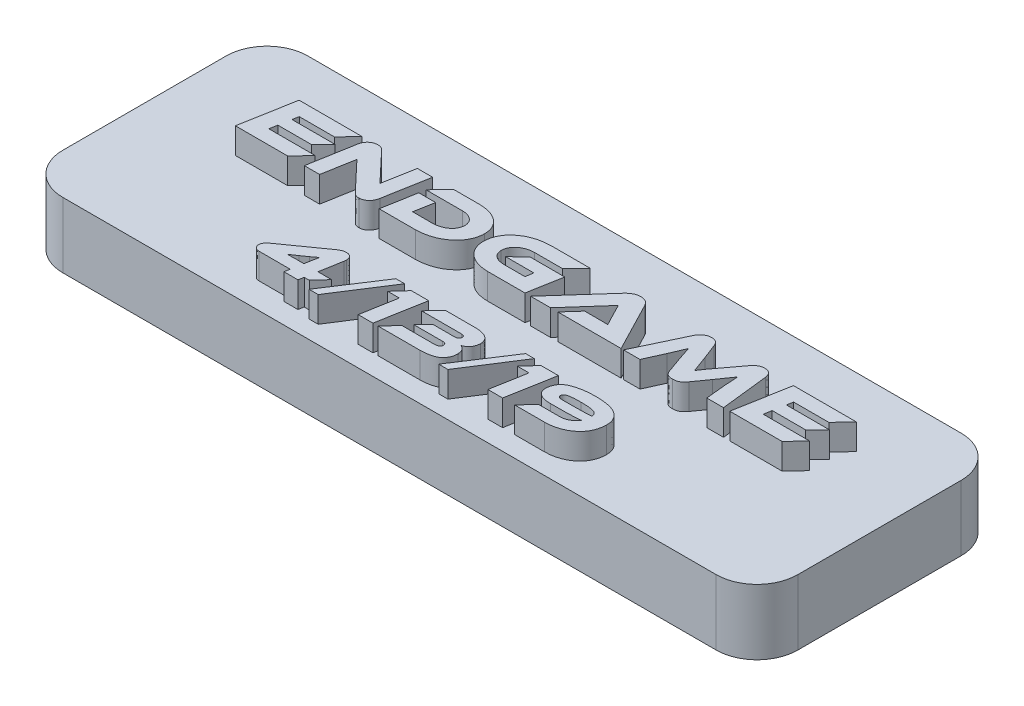
from build123d import *

# Parameters (mm, degrees)
SKETCH1_W           = 57.15
SKETCH1_H           = 19.05
BOSS_EXTRUDE1_DEPTH = 5.08
FILLET1_R           = 3.175
BOSS_EXTRUDE2_DEPTH = 2
SKETCH4_R           = 0.9
CUT_EXTRUDE1_DEPTH  = 4


with BuildPart() as part:
    # Sketch1 → Boss-Extrude1 (new body)
    with BuildSketch(Plane(origin=(0, 0, 0), x_dir=(1, 0, 0), z_dir=(0, 1, 0))):
        Rectangle(SKETCH1_W, SKETCH1_H)
    extrude(amount=BOSS_EXTRUDE1_DEPTH)

    # Fillet1
    fillet1_edges = [part.edges().sort_by_distance(p)[0] for p in [
        (-28.575, 2.54, -9.525),
        (-28.575, 2.54, 9.525),
        (28.575, 2.54, 9.525),
        (28.575, 2.54, -9.525),
    ]]
    fillet(fillet1_edges, radius=FILLET1_R)

    # Sketch3 → Boss-Extrude2 (add)
    with BuildSketch(Plane(origin=(0, 5.08, 0), x_dir=(1, 0, 0), z_dir=(0, 1, 0))):
        Polygon((18.429854665, 1.105536066), (18.530954449, 1.700326644), (21.13427389, 1.700326644), (22.044171947, 2.629107706), (18.701560334, 2.629107706), (18.790022645, 3.106887389), (21.526035553, 3.106887389), (22.568627077, 4.206347541), (17.67792502, 4.206347541), (16.925995376, 0.006075914), (20.995261687, 0.006075914), (22.031534474, 1.105536066), align=None)
        with BuildLine():
            add(Edge.make_bspline(
                [(11.894768833, 3.821864298), (11.880737461, 3.854947842), (11.853285062, 3.919675843), (11.798988796, 4.00785825), (11.735456865, 4.084680144), (11.662386911, 4.150072297), (11.577518363, 4.202261522), (11.480660996, 4.239681634), (11.371815878, 4.261491707), (11.295700389, 4.264690453), (11.255985459, 4.266359469)],
                knots=[0, 0, 0, 0, 0.000107692, 0.0002107, 0.00030937, 0.000405859, 0.000503537, 0.000606581, 0.000715765, 0.000834889, 0.000834889, 0.000834889, 0.000834889], degree=3))
            add(Edge.make_bspline(
                [(11.255985459, 4.266359469), (11.214706682, 4.264911976), (11.13219538, 4.262018611), (11.010430174, 4.234270285), (10.892028221, 4.188827027), (10.778036614, 4.125361681), (10.668900145, 4.045413244), (10.572082708, 3.943118147), (10.482019182, 3.825335584), (10.43414462, 3.735707046), (10.409478309, 3.689527923)],
                knots=[0, 0, 0, 0, 0.000123685, 0.000247231, 0.000372524, 0.000503046, 0.00063761, 0.000776601, 0.000924145, 0.00108096, 0.00108096, 0.00108096, 0.00108096], degree=3))
            Line((10.409478309, 3.689527923), (8.665894478, 0.003655726))
            Line((8.665894478, 0.003655726), (9.948597989, 0.003655726))
            Line((9.948597989, 0.003655726), (10.605746585, 1.464481009))
            add(Edge.make_bspline(
                [(10.605746585, 1.464481009), (10.629976343, 1.519909601), (10.677604369, 1.628864646), (10.746475763, 1.789446184), (10.81374685, 1.942964846), (10.876502056, 2.090413825), (10.937079718, 2.230959426), (10.993771815, 2.365338229), (11.046652072, 2.493505747), (11.081070868, 2.576699716), (11.097836715, 2.617224589)],
                knots=[0, 0, 0, 0, 0.000181479, 0.000356729, 0.00052418, 0.000684305, 0.000837469, 0.000983313, 0.001121843, 0.001253412, 0.001253412, 0.001253412, 0.001253412], degree=3))
            add(Edge.make_bspline(
                [(11.097836715, 2.617224589), (11.108081431, 2.582146896), (11.129323951, 2.509412955), (11.164696468, 2.396952832), (11.201420628, 2.276154433), (11.244755778, 2.146346616), (11.292640294, 2.002632754), (11.348718581, 1.841123618), (11.413859329, 1.659810645), (11.459560152, 1.531826555), (11.483609952, 1.464475652)],
                knots=[0, 0, 0, 0, 0.000109626, 0.000227311, 0.000353666, 0.000488379, 0.000637834, 0.000808115, 0.001001264, 0.001215812, 0.001215812, 0.001215812, 0.001215812], degree=3))
            Line((11.483609952, 1.464475652), (11.86317515, 0.404912456))
            add(Edge.make_bspline(
                [(11.86317515, 0.404912456), (11.881349857, 0.359535583), (11.915305273, 0.27475894), (11.981270271, 0.165066891), (12.052568902, 0.079389949), (12.133630324, 0.020148619), (12.222151269, -0.017188774), (12.317484931, -0.042938659), (12.422049706, -0.056575195), (12.494630096, -0.05604004), (12.532145266, -0.05576343)],
                knots=[0, 0, 0, 0, 0.000146435, 0.000273581, 0.000382454, 0.000478632, 0.000571543, 0.000669118, 0.00077423, 0.000886686, 0.000886686, 0.000886686, 0.000886686], degree=3))
            add(Edge.make_bspline(
                [(12.532145266, -0.05576343), (12.569961467, -0.055992745), (12.644351441, -0.056443841), (12.753780632, -0.042717291), (12.857894085, -0.015563104), (12.959959217, 0.022829401), (13.061143184, 0.083036928), (13.162366171, 0.169070984), (13.266819016, 0.280708265), (13.331989983, 0.367692811), (13.366768406, 0.414112029)],
                knots=[0, 0, 0, 0, 0.00011337, 0.000223015, 0.000329662, 0.000435594, 0.000549104, 0.000680897, 0.00083287, 0.001006773, 0.001006773, 0.001006773, 0.001006773], degree=3))
            Line((13.366768406, 0.414112029), (14.118964083, 1.465200548))
            add(Edge.make_bspline(
                [(14.118964083, 1.465200548), (14.165146382, 1.529169794), (14.253544614, 1.651614289), (14.378329736, 1.828381807), (14.492043038, 1.987679293), (14.592602712, 2.133154937), (14.684430967, 2.266547935), (14.769117851, 2.390994455), (14.847251286, 2.508743118), (14.896811327, 2.584889894), (14.920831208, 2.621795362)],
                knots=[0, 0, 0, 0, 0.000236691, 0.000453055, 0.000649121, 0.000823842, 0.000983589, 0.001134958, 0.00127542, 0.001407521, 0.001407521, 0.001407521, 0.001407521], degree=3))
            add(Edge.make_bspline(
                [(14.920831208, 2.621795362), (14.923065179, 2.536757041), (14.927655935, 2.362005428), (14.941696449, 2.139966033), (14.954363921, 1.952236415), (14.967941561, 1.800289613), (14.981123904, 1.638717755), (14.991416816, 1.52784762), (14.996706039, 1.470874734)],
                knots=[0, 0, 0, 0, 0.000255182, 0.000524392, 0.000667354, 0.000819643, 0.000982028, 0.00115368, 0.00115368, 0.00115368, 0.00115368], degree=3))
            Line((14.996706039, 1.470874734), (15.142599398, 0.003655726))
            Line((15.142599398, 0.003655726), (16.444259118, 0.003655726))
            Line((16.444259118, 0.003655726), (16.027222509, 3.690201933))
            add(Edge.make_bspline(
                [(16.027222509, 3.690201933), (16.019857111, 3.735767572), (16.005783628, 3.822832418), (15.960936809, 3.942054526), (15.901954619, 4.044898175), (15.822923496, 4.125995793), (15.73265053, 4.189905999), (15.631096195, 4.235155569), (15.519214696, 4.262540065), (15.44114713, 4.265057293), (15.400762367, 4.266359469)],
                knots=[0, 0, 0, 0, 0.000138154, 0.000263979, 0.000379994, 0.000491206, 0.000600771, 0.000710019, 0.000822876, 0.000943824, 0.000943824, 0.000943824, 0.000943824], degree=3))
            add(Edge.make_bspline(
                [(15.400762367, 4.266359469), (15.358916862, 4.264315029), (15.277042771, 4.26031492), (15.158115287, 4.237458819), (15.047211105, 4.198932407), (14.945190224, 4.144580626), (14.849604654, 4.0797862), (14.762121925, 4.002630646), (14.678413771, 3.917859546), (14.63004088, 3.853756483), (14.605447874, 3.821166184)],
                knots=[0, 0, 0, 0, 0.000125572, 0.000245692, 0.000361916, 0.000476404, 0.000591519, 0.00070753, 0.000825838, 0.000948192, 0.000948192, 0.000948192, 0.000948192], degree=3))
            Line((14.605447874, 3.821166184), (13.714564947, 2.63063338))
            add(Edge.make_bspline(
                [(13.714564947, 2.63063338), (13.685472724, 2.592038973), (13.628867352, 2.516944994), (13.546514277, 2.40752977), (13.469984999, 2.303579542), (13.396432362, 2.207146967), (13.328694504, 2.115786728), (13.267011313, 2.029366729), (13.208270311, 1.950451781), (13.138704278, 1.854220433), (13.058823945, 1.742020151), (12.970171015, 1.614517972), (12.890683501, 1.49522478), (12.840481428, 1.418793145), (12.816447343, 1.382201739)],
                knots=[0, 0, 0, 0, 0.000144993, 0.000282116, 0.00041083, 0.000532231, 0.000645954, 0.000752012, 0.000850745, 0.000941075, 0.001108235, 0.001263934, 0.001406932, 0.001538268, 0.001538268, 0.001538268, 0.001538268], degree=3))
            add(Edge.make_bspline(
                [(12.816447343, 1.382201739), (12.80437003, 1.418805813), (12.778644152, 1.496776135), (12.735411884, 1.619692211), (12.687083553, 1.756361741), (12.631857618, 1.906038253), (12.57182889, 2.069898911), (12.504908525, 2.24675863), (12.432783261, 2.43736016), (12.382008888, 2.568503977), (12.35571343, 2.636421836)],
                knots=[0, 0, 0, 0, 0.000115632, 0.000246309, 0.000390878, 0.000550518, 0.00072492, 0.000914406, 0.001117803, 0.001336294, 0.001336294, 0.001336294, 0.001336294], degree=3))
            Line((12.35571343, 2.636421836), (11.894768833, 3.821864298))
        make_face()
        with BuildLine():
            Line((8.477148337, 0.006075914), (6.512021283, 3.800574494))
            add(Edge.make_bspline(
                [(6.512021283, 3.800574494), (6.493900339, 3.832806008), (6.457941675, 3.896765269), (6.393067986, 3.985575321), (6.315808499, 4.0630874), (6.230905587, 4.133983071), (6.133099693, 4.192399523), (6.020988544, 4.23493807), (5.894946717, 4.260058315), (5.806215784, 4.264204191), (5.760088068, 4.266359469)],
                knots=[0, 0, 0, 0, 0.000110886, 0.000220038, 0.000328642, 0.000438436, 0.000551159, 0.000668641, 0.000796469, 0.000934872, 0.000934872, 0.000934872, 0.000934872], degree=3))
            add(Edge.make_bspline(
                [(5.760088068, 4.266359469), (5.710276408, 4.264009128), (5.613545287, 4.259444915), (5.473506531, 4.230967468), (5.343227969, 4.187726952), (5.223493094, 4.126959855), (5.113811438, 4.055096369), (5.010610085, 3.977511138), (4.916303872, 3.892229282), (4.858921369, 3.830720556), (4.83039285, 3.800140628)],
                knots=[0, 0, 0, 0, 0.00014941, 0.000290146, 0.000427171, 0.000560039, 0.000691642, 0.000820174, 0.000947034, 0.001072464, 0.001072464, 0.001072464, 0.001072464], degree=3))
            Line((4.83039285, 3.800140628), (1.444394604, 0.006075914))
            Line((1.444394604, 0.006075914), (2.992485048, 0.006075914))
            Line((2.992485048, 0.006075914), (5.469429759, 2.798493231))
            Line((5.469429759, 2.798493231), (6.031797308, 1.696826253))
            add(Edge.make_bspline(
                [(6.031797308, 1.696826253), (6.058471313, 1.644325557), (6.11298756, 1.5370248), (6.182415901, 1.403208105), (6.238498996, 1.297464771), (6.27964011, 1.223921613), (6.316043952, 1.155498073), (6.341342257, 1.112747401), (6.353374396, 1.092414734)],
                knots=[0, 0, 0, 0, 0.000176664, 0.000361065, 0.000452265, 0.000535729, 0.000613867, 0.000684736, 0.000684736, 0.000684736, 0.000684736], degree=3))
            add(Edge.make_bspline(
                [(6.353374396, 1.092414734), (6.297926051, 1.095166522), (6.179766216, 1.101030553), (5.995335681, 1.103502684), (5.800316815, 1.10564963), (5.668064218, 1.105358474), (5.601939324, 1.105212899)],
                knots=[0, 0, 0, 0, 0.000166537, 0.000354888, 0.000553268, 0.00075164, 0.00075164, 0.00075164, 0.00075164], degree=3))
            Line((5.601939324, 1.105212899), (4.546894229, 1.105536066))
            Line((4.546894229, 1.105536066), (3.561171334, 0.006075914))
            Line((3.561171334, 0.006075914), (8.477148337, 0.006075914))
        make_face()
        with BuildLine():
            Line((-2.188548578, 1.700326644), (0.00405299, 1.700326644))
            Line((0.00405299, 1.700326644), (-0.103365531, 1.105536066))
            Line((-0.103365531, 1.105536066), (-1.708324603, 1.105536066))
            add(Edge.make_bspline(
                [(-1.708324603, 1.105536066), (-1.748659925, 1.106330575), (-1.826997637, 1.10787364), (-1.941221904, 1.120440798), (-2.049065069, 1.138380554), (-2.150986128, 1.162855529), (-2.246335932, 1.194526626), (-2.334676568, 1.23455811), (-2.417480793, 1.27991048), (-2.493016882, 1.332827412), (-2.561129732, 1.391530884), (-2.621040822, 1.45559712), (-2.671500218, 1.52543391), (-2.713027543, 1.600393879), (-2.746069226, 1.680070217), (-2.769940723, 1.76505151), (-2.784594748, 1.855247878), (-2.787564667, 1.917233088), (-2.789085652, 1.948977585)],
                knots=[0, 0, 0, 0, 0.000120973, 0.00023495, 0.000344358, 0.000448788, 0.0005491, 0.00064526, 0.000739378, 0.000831943, 0.00092138, 0.001008705, 0.001094465, 0.001179171, 0.001265243, 0.001352639, 0.001443412, 0.001538699, 0.001538699, 0.001538699, 0.001538699], degree=3))
            add(Edge.make_bspline(
                [(-2.789085652, 1.948977585), (-2.786677572, 1.990521625), (-2.781933102, 2.072372891), (-2.758644466, 2.191747965), (-2.722646493, 2.305058921), (-2.675012901, 2.412475984), (-2.615297376, 2.514029002), (-2.542081222, 2.608456756), (-2.457439217, 2.697788244), (-2.360985687, 2.780121784), (-2.25556478, 2.8545346), (-2.14321074, 2.919811261), (-2.025243628, 2.975666019), (-1.901346883, 3.021489762), (-1.771588416, 3.057113773), (-1.635897555, 3.083377984), (-1.494184303, 3.101324142), (-1.397491818, 3.104622124), (-1.348378019, 3.106297295)],
                knots=[0, 0, 0, 0, 0.000124731, 0.000245749, 0.000363706, 0.00048075, 0.000597551, 0.000716215, 0.000838429, 0.000966139, 0.001096001, 0.001225039, 0.001355485, 0.001487088, 0.001620824, 0.001758691, 0.001901446, 0.002048806, 0.002048806, 0.002048806, 0.002048806], degree=3))
            Line((-1.348378019, 3.106297295), (0.831807473, 3.106887389))
            Line((0.831807473, 3.106887389), (1.874398996, 4.206347541))
            Line((1.874398996, 4.206347541), (-1.152275791, 4.206347541))
            add(Edge.make_bspline(
                [(-1.152275791, 4.206347541), (-1.25428659, 4.202659754), (-1.454076857, 4.195437147), (-1.747476329, 4.162798867), (-2.027131297, 4.108387385), (-2.294747671, 4.036898854), (-2.548411799, 3.943701994), (-2.790608821, 3.833597097), (-3.018377644, 3.700931434), (-3.197623245, 3.57590569), (-3.333148697, 3.468283005), (-3.427173439, 3.382481576), (-3.516376135, 3.295042371), (-3.598536123, 3.203531084), (-3.674403958, 3.108944431), (-3.745486418, 3.012406878), (-3.808356226, 2.911044995), (-3.865976767, 2.807132253), (-3.917479582, 2.700195689), (-3.961251359, 2.58966186), (-3.999599141, 2.476141564), (-4.032971617, 2.359497657), (-4.057835907, 2.239261797), (-4.078728774, 2.116507731), (-4.091018403, 1.990322157), (-4.095154311, 1.905118165), (-4.09724087, 1.862132899)],
                knots=[0, 0, 0, 0, 0.000306166, 0.000599632, 0.000884516, 0.001160163, 0.001429692, 0.001694339, 0.001957287, 0.002219254, 0.002349315, 0.002476175, 0.002600933, 0.00272392, 0.002844844, 0.002964612, 0.003083315, 0.003202384, 0.00332096, 0.003439109, 0.00355879, 0.003680341, 0.0038028, 0.003926937, 0.004053738, 0.004182841, 0.004182841, 0.004182841, 0.004182841], degree=3))
            add(Edge.make_bspline(
                [(-4.09724087, 1.862132899), (-4.094285472, 1.796195871), (-4.088495023, 1.667006815), (-4.057611951, 1.477974695), (-4.009464116, 1.297945273), (-3.942139409, 1.127082415), (-3.857736722, 0.964958447), (-3.754515321, 0.812395591), (-3.63298937, 0.669127744), (-3.494014468, 0.53618193), (-3.340474291, 0.41483463), (-3.172272609, 0.309152307), (-2.991924524, 0.218154431), (-2.797635671, 0.144712183), (-2.591482403, 0.084613249), (-2.371642784, 0.042790936), (-2.13957588, 0.013380205), (-1.980152443, 0.008154744), (-1.898699082, 0.005484928)],
                knots=[0, 0, 0, 0, 0.000197872, 0.000387686, 0.000573295, 0.000755955, 0.000937501, 0.001120561, 0.001307371, 0.001500038, 0.001696635, 0.001893441, 0.002094991, 0.002301602, 0.002515698, 0.002738365, 0.002972284, 0.003216652, 0.003216652, 0.003216652, 0.003216652], degree=3))
            Line((-1.898699082, 0.005484928), (1.002413358, 0.006075914))
            Line((1.002413358, 0.006075914), (1.46999986, 2.629107706))
            Line((1.46999986, 2.629107706), (-1.234419365, 2.629107706))
            Line((-1.234419365, 2.629107706), (-2.188548578, 1.700326644))
        make_face()
        with BuildLine():
            add(Edge.make_bspline(
                [(-4.549788457, 2.425376215), (-4.552664171, 2.490366785), (-4.558314581, 2.618064917), (-4.590121961, 2.803986167), (-4.638752569, 2.980115123), (-4.704286136, 3.146960648), (-4.790483292, 3.303299496), (-4.893914923, 3.450058323), (-5.016157304, 3.586303096), (-5.154716397, 3.712179584), (-5.3097238, 3.825344313), (-5.478138165, 3.925395962), (-5.6603537, 4.009390478), (-5.855217237, 4.079106767), (-6.063287079, 4.133528035), (-6.284486131, 4.173811565), (-6.518925776, 4.198189582), (-6.679671791, 4.203371321), (-6.762001498, 4.206025266)],
                knots=[0, 0, 0, 0, 0.000195009, 0.000383167, 0.000564368, 0.00074244, 0.000919581, 0.001098646, 0.001279935, 0.00146761, 0.001659228, 0.001854731, 0.002054318, 0.002260196, 0.002474835, 0.002698788, 0.00293411, 0.003181175, 0.003181175, 0.003181175, 0.003181175], degree=3))
            Line((-6.762001498, 4.206025266), (-8.758066971, 4.206347541))
            Line((-8.758066971, 4.206347541), (-9.788021021, 3.106887389))
            Line((-9.788021021, 3.106887389), (-6.957227066, 3.106887389))
            add(Edge.make_bspline(
                [(-6.957227066, 3.106887389), (-6.917715166, 3.105364711), (-6.840498924, 3.102389015), (-6.727877278, 3.089591847), (-6.621184262, 3.069582481), (-6.520335905, 3.04202105), (-6.424973819, 3.008030543), (-6.33684342, 2.964107485), (-6.253980142, 2.914773344), (-6.177216806, 2.858665576), (-6.109302126, 2.795181395), (-6.047623598, 2.72884043), (-5.99779337, 2.655711823), (-5.954979536, 2.579167986), (-5.920748824, 2.49778013), (-5.897753084, 2.411231968), (-5.881221869, 2.320728819), (-5.878495151, 2.258648084), (-5.877099855, 2.22688058)],
                knots=[0, 0, 0, 0, 0.000118592, 0.000231759, 0.000339692, 0.000443921, 0.000545141, 0.000642853, 0.0007388, 0.00083424, 0.000927403, 0.001017368, 0.001105364, 0.001192113, 0.001280223, 0.00136938, 0.001460305, 0.001555592, 0.001555592, 0.001555592, 0.001555592], degree=3))
            add(Edge.make_bspline(
                [(-5.877099855, 2.22688058), (-5.879544299, 2.185642711), (-5.884339039, 2.104755276), (-5.90687974, 1.98706422), (-5.940385994, 1.87545354), (-5.987513464, 1.770616802), (-6.046759093, 1.672112744), (-6.117047485, 1.579018173), (-6.201626674, 1.493971369), (-6.296064761, 1.414841832), (-6.400282041, 1.343689091), (-6.51193689, 1.281927096), (-6.629570344, 1.227960987), (-6.7548401, 1.185692043), (-6.886001438, 1.150471437), (-7.024349532, 1.126576329), (-7.168676339, 1.109169924), (-7.267474717, 1.106548421), (-7.317807488, 1.105212899)],
                knots=[0, 0, 0, 0, 0.00012382, 0.000242871, 0.000358539, 0.000472706, 0.000586683, 0.000702784, 0.000821729, 0.000945681, 0.001071953, 0.001199634, 0.001328098, 0.001459638, 0.001595783, 0.001735109, 0.00188048, 0.002031451, 0.002031451, 0.002031451, 0.002031451], degree=3))
            Line((-7.317807488, 1.105212899), (-8.833891809, 1.105536066))
            Line((-8.833891809, 1.105536066), (-8.562186139, 2.623662059))
            Line((-8.562186139, 2.623662059), (-9.870164596, 2.623662059))
            Line((-9.870164596, 2.623662059), (-10.337751098, 0.006075914))
            Line((-10.337751098, 0.006075914), (-7.506957142, 0.006075914))
            add(Edge.make_bspline(
                [(-7.506957142, 0.006075914), (-7.405089766, 0.00973645), (-7.204933829, 0.016928919), (-6.911556149, 0.055361686), (-6.630962616, 0.113609118), (-6.363086093, 0.192345638), (-6.107644027, 0.290947451), (-5.865467495, 0.411678855), (-5.635016854, 0.551302588), (-5.455642372, 0.685730436), (-5.320356032, 0.801137626), (-5.225165418, 0.891127884), (-5.135674869, 0.98286194), (-5.052781552, 1.077854124), (-4.976020105, 1.175378809), (-4.905844438, 1.275986307), (-4.841116497, 1.378755373), (-4.783986165, 1.484675691), (-4.732411112, 1.592866707), (-4.687522842, 1.703675086), (-4.649315903, 1.817381495), (-4.616218488, 1.933500983), (-4.589362309, 2.052449268), (-4.570885156, 2.174419147), (-4.556452898, 2.298802205), (-4.552603178, 2.38285802), (-4.549788457, 2.425376215)],
                knots=[0, 0, 0, 0, 0.000305659, 0.00060058, 0.000886364, 0.001164634, 0.001437273, 0.001706688, 0.001975409, 0.002244537, 0.002378097, 0.002508729, 0.002637378, 0.002762417, 0.002886772, 0.003009517, 0.003130255, 0.003250927, 0.003370328, 0.003489667, 0.003609348, 0.003730019, 0.003851781, 0.003974869, 0.004099948, 0.004227226, 0.004227226, 0.004227226, 0.004227226], degree=3))
        make_face()
        with BuildLine():
            add(Edge.make_bspline(
                [(-11.858368697, -0.054850168), (-11.8106253, -0.053307756), (-11.715923158, -0.05024828), (-11.577866776, -0.013632566), (-11.446952065, 0.045846546), (-11.345686531, 0.114571327), (-11.268821867, 0.180074196), (-11.217169586, 0.239380304), (-11.169493599, 0.304525883), (-11.125814852, 0.37632488), (-11.089085217, 0.456142621), (-11.055968596, 0.542520209), (-11.027538943, 0.636006561), (-11.012992869, 0.701351948), (-11.005507101, 0.73498029)],
                knots=[0, 0, 0, 0, 0.000142918, 0.000283487, 0.000425039, 0.000572601, 0.000649052, 0.000727397, 0.000807848, 0.000891096, 0.000979017, 0.001071034, 0.001168489, 0.001271817, 0.001271817, 0.001271817, 0.001271817], degree=3))
            Line((-11.005507101, 0.73498029), (-10.379784354, 4.208766837))
            Line((-10.379784354, 4.208766837), (-11.567706818, 4.208766837))
            Line((-11.567706818, 4.208766837), (-12.010018373, 1.744535481))
            Line((-12.010018373, 1.744535481), (-14.189982468, 4.051761679))
            add(Edge.make_bspline(
                [(-14.189982468, 4.051761679), (-14.210821595, 4.071861366), (-14.250885868, 4.110504029), (-14.313463732, 4.159915527), (-14.375501478, 4.198286334), (-14.45533886, 4.234148727), (-14.555615428, 4.262967857), (-14.636937859, 4.265244744), (-14.676751932, 4.266359469)],
                knots=[0, 0, 0, 0, 8.6821e-05, 0.000166918, 0.000238724, 0.000304999, 0.000429193, 0.000548317, 0.000548317, 0.000548317, 0.000548317], degree=3))
            add(Edge.make_bspline(
                [(-14.676751932, 4.266359469), (-14.726028977, 4.264808905), (-14.823075565, 4.261755212), (-14.964218277, 4.225895662), (-15.097953982, 4.169094021), (-15.200512985, 4.10078741), (-15.277028217, 4.035125752), (-15.328903582, 3.976716804), (-15.377051971, 3.912614286), (-15.419114668, 3.840326612), (-15.456430267, 3.76109782), (-15.488001593, 3.674633708), (-15.516216378, 3.581734028), (-15.529299031, 3.516584051), (-15.536057246, 3.482928986)],
                knots=[0, 0, 0, 0, 0.000147522, 0.000290531, 0.000433852, 0.000581668, 0.000658119, 0.000735785, 0.0008155, 0.00089828, 0.000986201, 0.001077895, 0.001174211, 0.001277134, 0.001277134, 0.001277134, 0.001277134], degree=3))
            Line((-15.536057246, 3.482928986), (-16.148790785, 0.003655726))
            Line((-16.148790785, 0.003655726), (-14.960868322, 0.003655726))
            Line((-14.960868322, 0.003655726), (-14.524875503, 2.467622834))
            Line((-14.524875503, 2.467622834), (-12.344911408, 0.160396636))
            add(Edge.make_bspline(
                [(-12.344911408, 0.160396636), (-12.324194302, 0.140042889), (-12.284589404, 0.101132624), (-12.222457852, 0.052046216), (-12.162898025, 0.012533377), (-12.085369154, -0.024191848), (-11.983674973, -0.051598076), (-11.900645209, -0.054359084), (-11.858368697, -0.054850168)],
                knots=[0, 0, 0, 0, 8.7067e-05, 0.000166446, 0.000237191, 0.000300979, 0.000423168, 0.000549653, 0.000549653, 0.000549653, 0.000549653], degree=3))
        make_face()
        Polygon((-20.008517509, 1.105536066), (-19.907417725, 1.700326644), (-17.304098284, 1.700326644), (-16.394200227, 2.629107706), (-19.73681184, 2.629107706), (-19.648349528, 3.106887389), (-16.912336621, 3.106887389), (-15.869745097, 4.206347541), (-20.760447154, 4.206347541), (-21.512376798, 0.006075914), (-17.443110487, 0.006075914), (-16.4068377, 1.105536066), align=None)
        with BuildLine():
            Line((9.037471648, -6.970155942), (8.142215687, -7.932183575))
            Line((8.142215687, -7.932183575), (10.460393327, -7.932183575))
            add(Edge.make_bspline(
                [(10.460393327, -7.932183575), (10.550239584, -7.929777147), (10.726809287, -7.92504793), (10.98582015, -7.89377972), (11.233859481, -7.845456505), (11.470347796, -7.778119368), (11.695620596, -7.693257531), (11.909297067, -7.589683886), (12.111380515, -7.467776465), (12.269561576, -7.351552012), (12.388796868, -7.251102183), (12.472146657, -7.171271707), (12.550671676, -7.089073015), (12.623886864, -7.003301544), (12.690626319, -6.913691428), (12.752960305, -6.821436558), (12.808521776, -6.725101624), (12.860176433, -6.626227548), (12.904835848, -6.523415525), (12.944006789, -6.417304195), (12.978646885, -6.308297587), (13.006250776, -6.195383605), (13.030001976, -6.079711014), (13.046047681, -5.960192069), (13.058685586, -5.837767761), (13.062033514, -5.75491021), (13.063726159, -5.713019076)],
                knots=[0, 0, 0, 0, 0.000269512, 0.000529657, 0.000781592, 0.001026938, 0.001266417, 0.001502887, 0.001738287, 0.001973466, 0.00209094, 0.002205793, 0.002319514, 0.002431869, 0.002543853, 0.002654555, 0.002765679, 0.002877297, 0.002989052, 0.003101677, 0.003216532, 0.003331962, 0.003450243, 0.003570604, 0.003693573, 0.003819318, 0.003819318, 0.003819318, 0.003819318], degree=3))
            add(Edge.make_bspline(
                [(13.063726159, -5.713019076), (13.061601039, -5.652117472), (13.057467249, -5.533651456), (13.029078622, -5.361744864), (12.98278984, -5.20161806), (12.918568557, -5.05300733), (12.835950893, -4.916595218), (12.736422554, -4.79126316), (12.616721793, -4.67984859), (12.481267506, -4.578328397), (12.326565022, -4.490460709), (12.154830881, -4.413762538), (11.96515105, -4.349318484), (11.758087074, -4.296844754), (11.533226109, -4.256528236), (11.290716399, -4.227593809), (11.030455012, -4.208531898), (10.851012539, -4.206884801), (10.758456824, -4.206035236)],
                knots=[0, 0, 0, 0, 0.00018267, 0.00035533, 0.000521131, 0.000681619, 0.000839513, 0.000998287, 0.001160113, 0.00132873, 0.001505033, 0.001692644, 0.001892226, 0.002105242, 0.002332894, 0.00257706, 0.002837673, 0.00311529, 0.00311529, 0.00311529, 0.00311529], degree=3))
            add(Edge.make_bspline(
                [(10.758456824, -4.206035236), (10.675257969, -4.205592276), (10.51171914, -4.204721577), (10.270480518, -4.215578286), (10.037659691, -4.234927868), (9.813233539, -4.265660573), (9.59708624, -4.305110003), (9.389664698, -4.355643498), (9.190744491, -4.415783415), (9.031299974, -4.473503284), (8.909439756, -4.525130752), (8.824973411, -4.569635858), (8.744965734, -4.616422557), (8.671758705, -4.668834502), (8.602879168, -4.723868288), (8.540670879, -4.784450305), (8.482703114, -4.847987079), (8.431338059, -4.916899938), (8.384956473, -4.989145242), (8.344775614, -5.066161285), (8.30953322, -5.146801308), (8.279968113, -5.2318633), (8.255964093, -5.32088445), (8.237698564, -5.41389817), (8.224674951, -5.510872203), (8.220794612, -5.57700115), (8.218821105, -5.610633762)],
                knots=[0, 0, 0, 0, 0.000249565, 0.000490555, 0.000724179, 0.0009502, 0.001169841, 0.001383052, 0.001590297, 0.00179299, 0.001891509, 0.001987031, 0.002079216, 0.002169319, 0.002256891, 0.002343445, 0.002429536, 0.002514644, 0.002600961, 0.002686833, 0.002774954, 0.002864759, 0.002956732, 0.003051325, 0.003148954, 0.003249996, 0.003249996, 0.003249996, 0.003249996], degree=3))
            add(Edge.make_bspline(
                [(8.218821105, -5.610633762), (8.220255959, -5.643753438), (8.223061456, -5.708510641), (8.23894285, -5.802650158), (8.265930264, -5.890402518), (8.300733481, -5.972873051), (8.346850863, -6.048807605), (8.403415213, -6.117637999), (8.469026306, -6.18094304), (8.544490807, -6.237416652), (8.628456868, -6.287658407), (8.72048282, -6.330947125), (8.820089213, -6.367615523), (8.927528008, -6.398128227), (9.042903094, -6.420818141), (9.165761914, -6.437537883), (9.296088771, -6.448004733), (9.385567354, -6.449663014), (9.431447168, -6.450513291)],
                knots=[0, 0, 0, 0, 9.9392e-05, 0.000194336, 0.000285432, 0.000374287, 0.00046222, 0.000550917, 0.000640864, 0.000735091, 0.000833037, 0.000933937, 0.001039728, 0.001151139, 0.001268635, 0.001392165, 0.00152296, 0.001660599, 0.001660599, 0.001660599, 0.001660599], degree=3))
            add(Edge.make_bspline(
                [(9.431447168, -6.450513291), (9.485039674, -6.450588766), (9.589825715, -6.450736339), (9.743402417, -6.449683936), (9.890314733, -6.448934551), (10.030294945, -6.448155746), (10.163608234, -6.447263447), (10.289995913, -6.446777451), (10.409706837, -6.444902162), (10.522758742, -6.443402764), (10.628874015, -6.441665317), (10.728075514, -6.440519694), (10.820568594, -6.437415789), (10.906184612, -6.436504009), (10.985094041, -6.433778787), (11.057080331, -6.43134803), (11.122437058, -6.429349577), (11.199177449, -6.424605461), (11.28643585, -6.420771207), (11.383704275, -6.413793257), (11.472303627, -6.408049685), (11.552177546, -6.400065169), (11.623563214, -6.394706302), (11.685854484, -6.386176476), (11.739515612, -6.378534723), (11.772193577, -6.372485855), (11.787109275, -6.369724879)],
                knots=[0, 0, 0, 0, 0.000160777, 0.000314357, 0.000460738, 0.00060152, 0.000734304, 0.000860688, 0.000980681, 0.001093477, 0.001199873, 0.001299072, 0.00139109, 0.001477493, 0.001555918, 0.001627948, 0.001693582, 0.001752061, 0.001858593, 0.001955591, 0.002044608, 0.00212492, 0.002196397, 0.002259299, 0.002313485, 0.002358987, 0.002358987, 0.002358987, 0.002358987], degree=3))
            add(Edge.make_bspline(
                [(11.787109275, -6.369724879), (11.757388219, -6.410755391), (11.697542947, -6.493372984), (11.589848846, -6.604032197), (11.469924752, -6.70577684), (11.359381789, -6.780745718), (11.264425747, -6.833676621), (11.189625994, -6.868964979), (11.11238554, -6.899761591), (11.031493621, -6.923136897), (10.94841744, -6.943784293), (10.861700027, -6.957621584), (10.772283089, -6.967749518), (10.711558976, -6.969535864), (10.680867953, -6.970438714)],
                knots=[0, 0, 0, 0, 0.000151822, 0.000305704, 0.000461788, 0.000623076, 0.000705429, 0.000787724, 0.000871054, 0.000954565, 0.001040123, 0.001127702, 0.001217802, 0.001309875, 0.001309875, 0.001309875, 0.001309875], degree=3))
            Line((10.680867953, -6.970438714), (9.037471648, -6.970155942))
        make_face()
        with BuildLine():
            add(Edge.make_bspline(
                [(9.647645844, -5.739416071), (9.619260826, -5.739333167), (9.566072111, -5.739177819), (9.492321783, -5.728388524), (9.429434379, -5.712937853), (9.377511234, -5.691097621), (9.336391999, -5.66209877), (9.308177259, -5.625127048), (9.290044971, -5.582069955), (9.288874274, -5.550830586), (9.288267705, -5.534644662)],
                knots=[0, 0, 0, 0, 8.5051e-05, 0.000159372, 0.000223007, 0.000278884, 0.00032752, 0.000371998, 0.000416856, 0.000465088, 0.000465088, 0.000465088, 0.000465088], degree=3))
            add(Edge.make_bspline(
                [(9.288267705, -5.534644662), (9.287065419, -5.520492659), (9.284711493, -5.492784798), (9.292658168, -5.451904192), (9.307938057, -5.413284736), (9.332852391, -5.377865243), (9.365139393, -5.344746874), (9.406404298, -5.315137149), (9.455032714, -5.287204256), (9.513516416, -5.262102266), (9.584011361, -5.239181686), (9.670150249, -5.220969825), (9.772092382, -5.204302076), (9.890363974, -5.19102051), (10.024831798, -5.180808804), (10.175822962, -5.174134861), (10.343015577, -5.169033665), (10.459828414, -5.168550026), (10.5208909, -5.16829721)],
                knots=[0, 0, 0, 0, 4.2424e-05, 8.3061e-05, 0.000123611, 0.000166209, 0.000212026, 0.00026178, 0.000318034, 0.000380003, 0.000452348, 0.000540062, 0.000643816, 0.000762183, 0.000896965, 0.001048315, 0.00121556, 0.00139874, 0.00139874, 0.00139874, 0.00139874], degree=3))
            add(Edge.make_bspline(
                [(10.5208909, -5.16829721), (10.573417429, -5.167787601), (10.675543344, -5.166796781), (10.824088142, -5.169363834), (10.963368239, -5.174373781), (11.093194618, -5.184530804), (11.213890889, -5.195834798), (11.325273517, -5.211544935), (11.427013036, -5.232098586), (11.520225985, -5.253456427), (11.603846744, -5.280784321), (11.677336699, -5.316195779), (11.739979011, -5.359607715), (11.793547245, -5.409671023), (11.835288262, -5.468468051), (11.868142914, -5.534032814), (11.888589751, -5.607713922), (11.894471714, -5.659314386), (11.897493442, -5.685822977)],
                knots=[0, 0, 0, 0, 0.000157579, 0.000306377, 0.00044567, 0.000575606, 0.000696984, 0.000809313, 0.000912848, 0.001008299, 0.001096072, 0.001176204, 0.001252088, 0.00132394, 0.001394981, 0.001467241, 0.001542944, 0.00162292, 0.00162292, 0.00162292, 0.00162292], degree=3))
            add(Edge.make_bspline(
                [(11.897493442, -5.685822977), (11.879902738, -5.688016622), (11.842355272, -5.692698971), (11.782598188, -5.698817251), (11.716023393, -5.705774202), (11.642596325, -5.709867374), (11.562620569, -5.714809123), (11.475984017, -5.719762177), (11.382653256, -5.723691176), (11.279453651, -5.726773296), (11.160283793, -5.730355113), (11.01868678, -5.73231403), (10.851779395, -5.734779827), (10.659809902, -5.737306699), (10.442504427, -5.738848781), (10.199870139, -5.739352636), (9.93190951, -5.740463735), (9.745002328, -5.740300435), (9.647645844, -5.739416071)],
                knots=[0, 0, 0, 0, 5.3179e-05, 0.000113511, 0.000180209, 0.000253954, 0.000334087, 0.000420608, 0.00051428, 0.000614317, 0.000730344, 0.000871944, 0.001039137, 0.001231125, 0.0014479, 0.001691066, 0.001959029, 0.002251787, 0.002251787, 0.002251787, 0.002251787], degree=3))
        make_face(mode=Mode.SUBTRACT)
        Polygon((5.641029922, -5.218973535), (6.542239716, -5.218973535), (6.0612259, -7.93430124), (7.20570705, -7.93430124), (7.863645488, -4.256945902), (6.50906635, -4.256945902), align=None)
        Polygon((5.109068726, -4.05005839), (2.444141604, -8.139071868), (3.157368987, -8.139071868), (5.783593848, -4.05005839), align=None)
        with BuildLine():
            Line((-2.484276472, -7.932183575), (0.772242356, -7.932183575))
            add(Edge.make_bspline(
                [(0.772242356, -7.932183575), (0.814258653, -7.93123587), (0.896583349, -7.929378983), (1.017579239, -7.923037277), (1.133297114, -7.913254577), (1.244072374, -7.901623973), (1.349373793, -7.886187648), (1.449559297, -7.869042189), (1.544158466, -7.847894486), (1.63338841, -7.825100472), (1.717503917, -7.799290342), (1.796031832, -7.77082736), (1.869622872, -7.739583859), (1.93746295, -7.704897995), (2.000990068, -7.668886302), (2.057900823, -7.627851966), (2.110923206, -7.586408565), (2.172147393, -7.526093275), (2.240358988, -7.447939794), (2.31093604, -7.349103621), (2.370703995, -7.247349748), (2.418208772, -7.141977162), (2.453682225, -7.033365496), (2.476960247, -6.921258258), (2.488393243, -6.805632209), (2.486832588, -6.727558847), (2.486043406, -6.688079215)],
                knots=[0, 0, 0, 0, 0.000126077, 0.000247029, 0.000363409, 0.000474443, 0.000581116, 0.000682639, 0.000779289, 0.000871831, 0.000958868, 0.001043129, 0.001122322, 0.001198517, 0.00127164, 0.001341101, 0.001408809, 0.001473297, 0.001598583, 0.001719557, 0.001837129, 0.001952051, 0.002065626, 0.002179204, 0.002294931, 0.002413314, 0.002413314, 0.002413314, 0.002413314], degree=3))
            add(Edge.make_bspline(
                [(2.486043406, -6.688079215), (2.484020763, -6.645034748), (2.48012822, -6.562196351), (2.455583298, -6.444259027), (2.41436978, -6.339492999), (2.358920806, -6.247902175), (2.290140279, -6.171048672), (2.2123217, -6.10652163), (2.124244976, -6.055707807), (2.059638561, -6.034777591), (2.026909263, -6.024174444)],
                knots=[0, 0, 0, 0, 0.000129139, 0.000248525, 0.000359482, 0.000465388, 0.000567951, 0.000667397, 0.000767703, 0.000870689, 0.000870689, 0.000870689, 0.000870689], degree=3))
            add(Edge.make_bspline(
                [(2.026909263, -6.024174444), (2.068239919, -6.009960653), (2.151524069, -5.981318874), (2.267984233, -5.914739414), (2.377711242, -5.831227741), (2.462535929, -5.748532962), (2.523927, -5.672798575), (2.565254066, -5.610121102), (2.599341797, -5.541280496), (2.628987733, -5.468161351), (2.652499537, -5.389726388), (2.668552372, -5.306040388), (2.681263227, -5.217443624), (2.683877861, -5.156345524), (2.685214837, -5.125103406)],
                knots=[0, 0, 0, 0, 0.000130881, 0.000263734, 0.000400196, 0.000543864, 0.000617818, 0.000692362, 0.000768557, 0.000847875, 0.000928857, 0.001013724, 0.001103318, 0.001197072, 0.001197072, 0.001197072, 0.001197072], degree=3))
            add(Edge.make_bspline(
                [(2.685214837, -5.125103406), (2.683875091, -5.090373417), (2.6812721, -5.022896543), (2.664225373, -4.924759117), (2.636158106, -4.833556952), (2.598420813, -4.74840209), (2.549889423, -4.670190772), (2.491227695, -4.598383368), (2.421177379, -4.534139714), (2.34202433, -4.475547046), (2.252692967, -4.424861588), (2.155534934, -4.380021469), (2.050238639, -4.341403135), (1.936448486, -4.310565354), (1.814548814, -4.286619559), (1.684379657, -4.270262105), (1.546083353, -4.259706834), (1.451011878, -4.258068877), (1.402198871, -4.257227893)],
                knots=[0, 0, 0, 0, 0.000104182, 0.000202415, 0.000297803, 0.000389821, 0.000481053, 0.000573127, 0.000667078, 0.000765468, 0.000867956, 0.000974605, 0.001086203, 0.001203992, 0.00132792, 0.001458586, 0.001597356, 0.00174379, 0.00174379, 0.00174379, 0.00174379], degree=3))
            Line((1.402198871, -4.257227893), (-0.91407045, -4.256945902))
            Line((-0.91407045, -4.256945902), (-1.820809138, -5.218973535))
            Line((-1.820809138, -5.218973535), (1.27537175, -5.218973535))
            add(Edge.make_bspline(
                [(1.27537175, -5.218973535), (1.293424629, -5.219195663), (1.328510444, -5.219627369), (1.379249442, -5.228283394), (1.426909514, -5.240429742), (1.469714491, -5.259411957), (1.507251806, -5.284007636), (1.535554388, -5.317589756), (1.551693281, -5.359825366), (1.554894116, -5.390000635), (1.556576727, -5.405863134)],
                knots=[0, 0, 0, 0, 5.4079e-05, 0.000105103, 0.000154, 0.000201268, 0.000244977, 0.000287582, 0.000330657, 0.000378396, 0.000378396, 0.000378396, 0.000378396], degree=3))
            add(Edge.make_bspline(
                [(1.556576727, -5.405863134), (1.554738409, -5.430312402), (1.551263648, -5.476526055), (1.529434098, -5.540002066), (1.494147897, -5.592061965), (1.445136753, -5.629761186), (1.388822643, -5.655905201), (1.327607223, -5.675731181), (1.261290474, -5.686777079), (1.215331328, -5.68773353), (1.191829046, -5.688222633)],
                knots=[0, 0, 0, 0, 7.3319e-05, 0.000138587, 0.00019894, 0.000259277, 0.000321525, 0.000384513, 0.000451841, 0.000522304, 0.000522304, 0.000522304, 0.000522304], degree=3))
            Line((1.191829046, -5.688222633), (-0.449643316, -5.688222633))
            Line((-0.449643316, -5.688222633), (-1.184986277, -6.449714187))
            Line((-1.184986277, -6.449714187), (1.032100395, -6.449714187))
            add(Edge.make_bspline(
                [(1.032100395, -6.449714187), (1.057658526, -6.450477347), (1.105361742, -6.451901753), (1.171901575, -6.462295485), (1.228320835, -6.478314945), (1.274984307, -6.50173535), (1.311224628, -6.532597577), (1.337218232, -6.570559095), (1.350989292, -6.615980043), (1.352047695, -6.647995141), (1.352605984, -6.664882542)],
                knots=[0, 0, 0, 0, 7.6645e-05, 0.000143055, 0.000201512, 0.000251956, 0.000298459, 0.000342829, 0.000388113, 0.000438664, 0.000438664, 0.000438664, 0.000438664], degree=3))
            add(Edge.make_bspline(
                [(1.352605984, -6.664882542), (1.352129981, -6.688229704), (1.351220563, -6.732835091), (1.331993099, -6.795336816), (1.300424863, -6.849505947), (1.253205227, -6.892453142), (1.194552993, -6.927804649), (1.121571984, -6.950272738), (1.036850584, -6.966892139), (0.975694387, -6.969204801), (0.943064728, -6.970438714)],
                knots=[0, 0, 0, 0, 6.9755e-05, 0.000133269, 0.000193903, 0.000255577, 0.000322658, 0.000397783, 0.000483281, 0.000581077, 0.000581077, 0.000581077, 0.000581077], degree=3))
            Line((0.943064728, -6.970438714), (-1.588595572, -6.970155942))
            Line((-1.588595572, -6.970155942), (-2.484276472, -7.932183575))
        make_face()
        Polygon((-4.443923508, -5.218973535), (-3.542713714, -5.218973535), (-4.02372753, -7.93430124), (-2.87924638, -7.93430124), (-2.221307942, -4.256945902), (-3.57588708, -4.256945902), align=None)
        Polygon((-4.975884704, -4.05005839), (-7.640811826, -8.139071868), (-6.927584443, -8.139071868), (-4.301359582, -4.05005839), align=None)
        with BuildLine():
            Line((-9.724916011, -7.520594175), (-9.802320533, -7.93430124))
            Line((-9.802320533, -7.93430124), (-8.707599433, -7.93430124))
            Line((-8.707599433, -7.93430124), (-8.630194911, -7.520594175))
            Line((-8.630194911, -7.520594175), (-8.2431723, -7.520594175))
            Line((-8.2431723, -7.520594175), (-7.413838133, -6.613855487))
            Line((-7.413838133, -6.613855487), (-8.475385866, -6.613855487))
            Line((-8.475385866, -6.613855487), (-8.171296672, -4.894612248))
            add(Edge.make_bspline(
                [(-8.171296672, -4.894612248), (-8.16643527, -4.864321659), (-8.156746189, -4.803950598), (-8.155467435, -4.742821019), (-8.154830284, -4.712362609)],
                knots=[0, 0, 0, 0, 9.1912e-05, 0.000183187, 0.000183187, 0.000183187, 0.000183187], degree=3))
            add(Edge.make_bspline(
                [(-8.154830284, -4.712362609), (-8.155527065, -4.6907417), (-8.156873933, -4.648948846), (-8.164846387, -4.588663196), (-8.177880758, -4.533098056), (-8.194184368, -4.481981392), (-8.215581845, -4.435403393), (-8.240549067, -4.39290306), (-8.271762218, -4.355875929), (-8.317497236, -4.312019012), (-8.384080376, -4.268282081), (-8.472820306, -4.230068234), (-8.570942415, -4.207057185), (-8.639435048, -4.205327459), (-8.674755707, -4.204435465)],
                knots=[0, 0, 0, 0, 6.487e-05, 0.000125392, 0.000182048, 0.000235927, 0.000286039, 0.000335561, 0.000383287, 0.000430811, 0.000525319, 0.000620267, 0.000719611, 0.000825389, 0.000825389, 0.000825389, 0.000825389], degree=3))
            add(Edge.make_bspline(
                [(-8.674755707, -4.204435465), (-8.692899217, -4.204980307), (-8.730913299, -4.206121854), (-8.79103814, -4.21327143), (-8.856115593, -4.228757289), (-8.927116567, -4.24699065), (-9.001497413, -4.273748693), (-9.078284633, -4.307912525), (-9.156063814, -4.351603952), (-9.20689666, -4.38540133), (-9.233075622, -4.402807011)],
                knots=[0, 0, 0, 0, 5.4445e-05, 0.000114073, 0.000181225, 0.000254958, 0.000333892, 0.000418032, 0.000506833, 0.000601128, 0.000601128, 0.000601128, 0.000601128], degree=3))
            Line((-9.233075622, -4.402807011), (-12.284794138, -6.56963058))
            add(Edge.make_bspline(
                [(-12.284794138, -6.56963058), (-12.311248117, -6.590810858), (-12.361851124, -6.631325964), (-12.428938131, -6.696764533), (-12.484863274, -6.7623047), (-12.531413181, -6.827079539), (-12.566241881, -6.892522378), (-12.590753698, -6.958059845), (-12.605072865, -7.023928319), (-12.605822824, -7.067959349), (-12.606191787, -7.089621618)],
                knots=[0, 0, 0, 0, 0.00010162, 0.000194386, 0.000280626, 0.000359851, 0.000433205, 0.000502297, 0.000569282, 0.000634152, 0.000634152, 0.000634152, 0.000634152], degree=3))
            add(Edge.make_bspline(
                [(-12.606191787, -7.089621618), (-12.604709414, -7.118591013), (-12.601817131, -7.175113703), (-12.577529062, -7.255822597), (-12.539141347, -7.329482478), (-12.486240373, -7.395411266), (-12.418536897, -7.450617536), (-12.335775795, -7.490141442), (-12.240192875, -7.515111941), (-12.171751591, -7.518816836), (-12.135859251, -7.520759777)],
                knots=[0, 0, 0, 0, 8.6757e-05, 0.000169273, 0.000250488, 0.000334685, 0.000421132, 0.000510207, 0.000607797, 0.00071541, 0.00071541, 0.00071541, 0.00071541], degree=3))
            Line((-12.135859251, -7.520759777), (-9.724916011, -7.520594175))
        make_face()
        with BuildLine():
            Line((-9.564578072, -6.613855487), (-10.228045405, -6.613855487))
            add(Edge.make_bspline(
                [(-10.228045405, -6.613855487), (-10.2915369, -6.614087024), (-10.411038851, -6.614522818), (-10.578778759, -6.618813835), (-10.723736696, -6.623863417), (-10.812340736, -6.632252066), (-10.852843285, -6.636086673)],
                knots=[0, 0, 0, 0, 0.000190466, 0.000358489, 0.00050341, 0.000625436, 0.000625436, 0.000625436, 0.000625436], degree=3))
            add(Edge.make_bspline(
                [(-10.852843285, -6.636086673), (-10.814029332, -6.612329849), (-10.730239816, -6.561044871), (-10.599161088, -6.47333578), (-10.451305851, -6.372579941), (-10.348754178, -6.299033186), (-10.29452337, -6.260140598)],
                knots=[0, 0, 0, 0, 0.000136509, 0.000294688, 0.000473068, 0.000673265, 0.000673265, 0.000673265, 0.000673265], degree=3))
            Line((-10.29452337, -6.260140598), (-9.829965005, -5.93389755))
            add(Edge.make_bspline(
                [(-9.829965005, -5.93389755), (-9.781529932, -5.899629074), (-9.690301601, -5.835083783), (-9.56393861, -5.742002288), (-9.457525275, -5.658449591), (-9.394504316, -5.604680291), (-9.365856576, -5.580238122)],
                knots=[0, 0, 0, 0, 0.000177993, 0.000335254, 0.000470796, 0.000583761, 0.000583761, 0.000583761, 0.000583761], degree=3))
            add(Edge.make_bspline(
                [(-9.365856576, -5.580238122), (-9.373994081, -5.612733173), (-9.391089017, -5.680997438), (-9.410713649, -5.769363291), (-9.426262461, -5.84710273), (-9.439453393, -5.912841199), (-9.451527681, -5.985328058), (-9.460952221, -6.035655941), (-9.465842234, -6.061769052)],
                knots=[0, 0, 0, 0, 0.000100493, 0.000211112, 0.000271507, 0.000338335, 0.000412241, 0.000491941, 0.000491941, 0.000491941, 0.000491941], degree=3))
            Line((-9.465842234, -6.061769052), (-9.564578072, -6.613855487))
        make_face(mode=Mode.SUBTRACT)
    extrude(amount=BOSS_EXTRUDE2_DEPTH)

    # Sketch4 → Cut-Extrude1 (cut)
    with BuildSketch(Plane.XZ):
        with Locations((-25.4, 0)):
            Circle(SKETCH4_R)
        with Locations((25.4, 0)):
            Circle(SKETCH4_R)
    extrude(amount=-CUT_EXTRUDE1_DEPTH, mode=Mode.SUBTRACT)


solid = part.part
